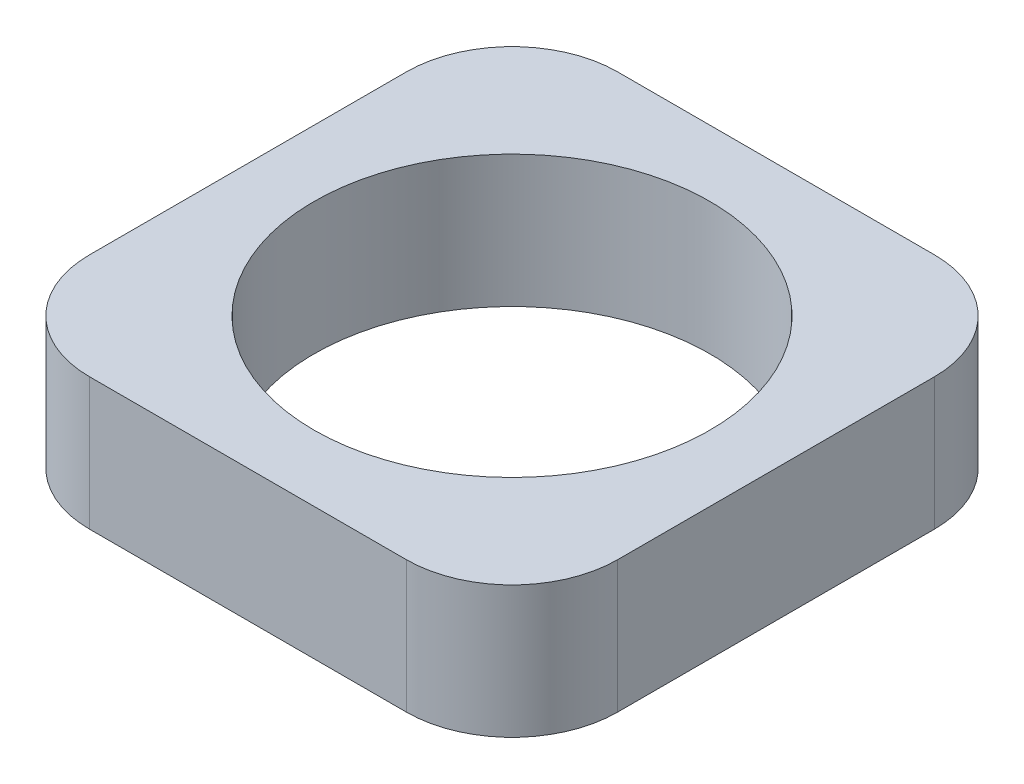
from build123d import *

# Parameters (mm, degrees)
SALIENTE_EXTRUIR1_DEPTH = 5
CROQUIS2_R              = 7.5
CORTAR_EXTRUIR1_DEPTH   = 6


with BuildPart() as part:
    # Croquis1 → Saliente-Extruir1 (new body)
    with BuildSketch(Plane(origin=(0, 0, 0), x_dir=(1, 0, 0), z_dir=(0, 1, 0))):
        with BuildLine():
            Line((-6, -10), (6, -10))
            ThreePointArc((6, -10), (8.828427125, -8.828427125), (10, -6))
            Line((10, -6), (10, 6))
            ThreePointArc((10, 6), (8.828427125, 8.828427125), (6, 10))
            Line((6, 10), (-6, 10))
            ThreePointArc((-6, 10), (-8.828427125, 8.828427125), (-10, 6))
            Line((-10, 6), (-10, -6))
            ThreePointArc((-10, -6), (-8.828427125, -8.828427125), (-6, -10))
        make_face()
    extrude(amount=SALIENTE_EXTRUIR1_DEPTH)

    # Croquis2 → Cortar-Extruir1 (cut, through all)
    with BuildSketch(Plane(origin=(0, 5, 0), x_dir=(1, 0, 0), z_dir=(0, 1, 0))):
        Circle(CROQUIS2_R)
    extrude(amount=-CORTAR_EXTRUIR1_DEPTH, mode=Mode.SUBTRACT)


solid = part.part
